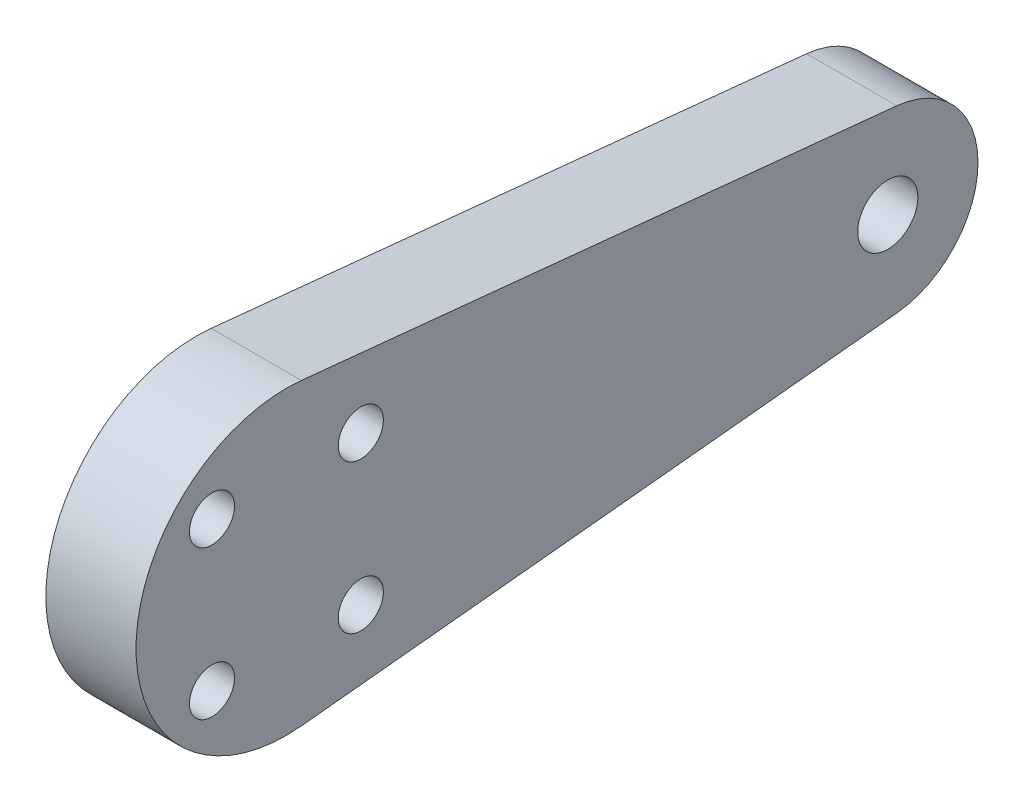
from build123d import *

# Parameters (mm, degrees)
SKETCH1_R               = 10
SKETCH1_R_2             = 6
BOSS_EXTRUDE1_DEPTH     = 3
SKETCH2_R               = 1.5
CUT_EXTRUDE1_DEPTH      = 4
CUT_EXTRUDE1_DEPTH_BACK = 4
F_4_0MM_DOWEL_HOLE1_D   = 4


with BuildPart() as part:
    # Sketch1 → Boss-Extrude1 (new body, symmetric)
    with BuildSketch(Plane(origin=(0, 0, 0), x_dir=(0, 0, -1), z_dir=(1, 0, 0))):
        Circle(SKETCH1_R)
        with BuildLine():
            ThreePointArc((40.6, -5.969924623), (34, 0), (40.6, 5.969924623))
            Line((40.6, 5.969924623), (1, 9.949874371))
            ThreePointArc((1, 9.949874371), (7.416198487, 6.708203932), (10, 0))
            ThreePointArc((10, 0), (7.416198487, -6.708203933), (1, -9.949874371))
            Line((1, -9.949874371), (40.6, -5.969924623))
        make_face()
        with Locations((40, 0)):
            Circle(SKETCH1_R_2)
    extrude(amount=BOSS_EXTRUDE1_DEPTH, both=True)

    # Sketch2 → Cut-Extrude1 (cut, two sides)
    with BuildSketch(Plane(origin=(0, 0, 0), x_dir=(0, 0, -1), z_dir=(1, 0, 0))) as cut_extrude1_sk:
        with Locations((4.949747468, 4.949747468)):
            Circle(SKETCH2_R)
        with Locations((4.949747468, -4.949747468)):
            Circle(SKETCH2_R)
        with Locations((-4.949747468, -4.949747468)):
            Circle(SKETCH2_R)
        with Locations((-4.949747468, 4.949747468)):
            Circle(SKETCH2_R)
    extrude(amount=CUT_EXTRUDE1_DEPTH, mode=Mode.SUBTRACT)
    extrude(cut_extrude1_sk.sketch, amount=-CUT_EXTRUDE1_DEPTH_BACK, mode=Mode.SUBTRACT)

    # 4.0mm Dowel Hole1 (through all)
    with Locations(Plane(origin=(3, 0, 0), x_dir=(0, 0, -1), z_dir=(1, 0, 0))):
        with Locations((40, 0)):
            Hole(F_4_0MM_DOWEL_HOLE1_D / 2)


solid = part.part
